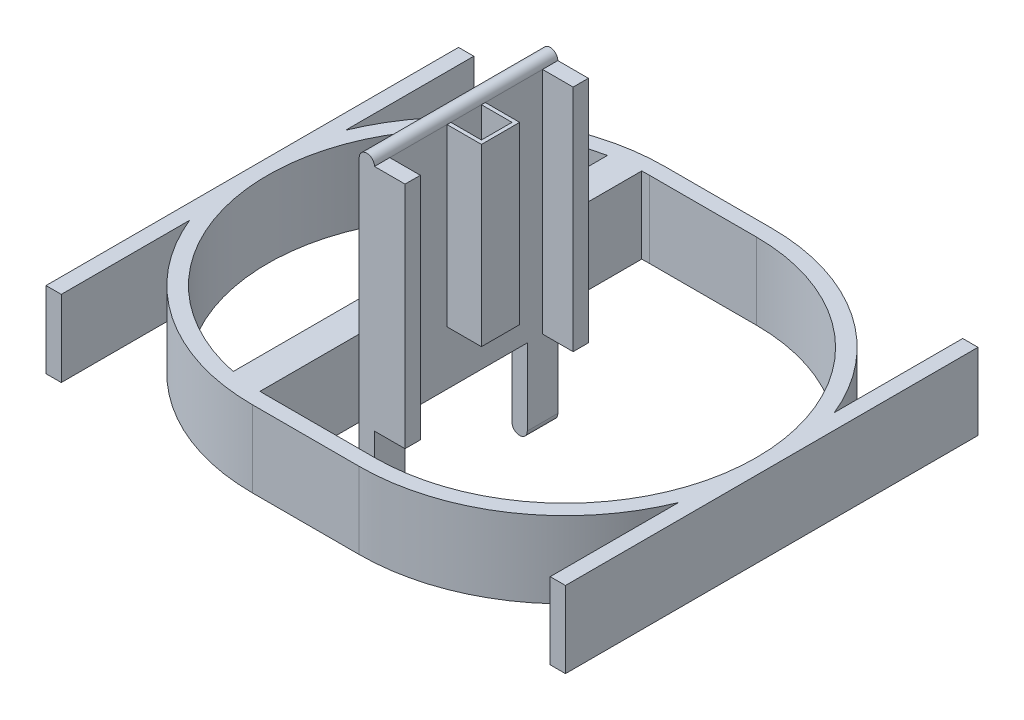
from build123d import *

# Parameters (mm, degrees)
EXTRUDE_1_DEPTH     = 10
SKETCH_9_W          = 24
SKETCH_9_H          = 40
EXTRUDE_5_DEPTH     = 2
SKETCH_10_R         = 1
EXTRUDE_6_DEPTH     = 24
SKETCH_11_W         = 16
SKETCH_11_H         = 15.152135862
CUT_EXTRUDE_2_DEPTH = 24
SKETCH_12_W         = 2
SKETCH_12_H         = 30
EXTRUDE_7_DEPTH     = 4
SKETCH_13_W         = 5
SKETCH_13_H         = 5
SKETCH_13_W_2       = 4
SKETCH_13_H_2       = 4
SKETCH_15_W         = 2
SKETCH_15_H         = 54
EXTRUDE_8_DEPTH     = 10


with BuildPart() as part:
    # 草图2 → 凸台-拉伸1 (new body)
    with BuildSketch(Plane(origin=(0, 0, 0), x_dir=(1, 0, 0), z_dir=(0, 1, 0))):
        with BuildLine():
            Line((-7, 27), (7, 27))
            ThreePointArc((7, 27), (34, 0), (7, -27))
            Line((7, -27), (-7, -27))
            ThreePointArc((-7, -27), (-34, 0), (-7, 27))
        make_face()
        with BuildLine():
            Line((-7, 25), (7, 25))
            ThreePointArc((7, 25), (32, 0), (7, -25))
            Line((7, -25), (-7, -25))
            ThreePointArc((-7, -25), (-7.50010007, -24.994997498), (-8, -24.979991994))
            Line((-8, -24.979991994), (-8, 24.979991994))
            ThreePointArc((-8, 24.979991994), (-7.50010007, 24.994997498), (-7, 25))
        make_face(mode=Mode.SUBTRACT)
        with BuildLine():
            Line((-12, -24.494897428), (-12, 24.494897428))
            ThreePointArc((-12, 24.494897428), (-32, 0), (-12, -24.494897428))
        make_face(mode=Mode.SUBTRACT)
    extrude(amount=EXTRUDE_1_DEPTH)

    # 草图9 → 凸台-拉伸5 (add)
    with BuildSketch(Plane(origin=(-8, 0, 0), x_dir=(0, 0, -1), z_dir=(1, 0, 0))):
        with Locations((0, 10)):
            Rectangle(SKETCH_9_W, SKETCH_9_H)
    extrude(amount=EXTRUDE_5_DEPTH)

    # 草图10 → 凸台-拉伸6 (add)
    with BuildSketch(Plane(origin=(0, 0, -12), x_dir=(-1, 0, 0), z_dir=(0, 0, -1))):
        with Locations((7, 30)):
            Circle(SKETCH_10_R)
        with Locations((7, -10)):
            Circle(SKETCH_10_R)
    extrude(amount=-EXTRUDE_6_DEPTH)

    # 草图11 → 切除-拉伸2 (cut)
    with BuildSketch(Plane(origin=(-6, 0, 0), x_dir=(0, 0, -1), z_dir=(1, 0, 0))):
        with Locations((0, -7.576067931)):
            Rectangle(SKETCH_11_W, SKETCH_11_H)
    extrude(amount=-CUT_EXTRUDE_2_DEPTH, mode=Mode.SUBTRACT)

    # 草图12 → 凸台-拉伸7 (add)
    with BuildSketch(Plane(origin=(-6, 0, 0), x_dir=(0, 0, -1), z_dir=(1, 0, 0))):
        with Locations((11, 15)):
            Rectangle(SKETCH_12_W, SKETCH_12_H)
        with Locations((-11, 15)):
            Rectangle(SKETCH_12_W, SKETCH_12_H)
    extrude(amount=EXTRUDE_7_DEPTH)

    # 扫描3: sweep along a path in 草图14
    with BuildLine(Plane(origin=(-6, 0, 0), x_dir=(0, 0, -1), z_dir=(1, 0, 0))) as sweep_3_path:
        Line((-2, 7.068163289), (-2, 30))
    # 草图13 → 扫描3 (sweep)
    with BuildSketch(Plane(origin=(0, 30, 0), x_dir=(1, 0, 0), z_dir=(0, 1, 0))):
        with Locations((-4, 0)):
            Rectangle(SKETCH_13_W, SKETCH_13_H)
        with Locations((-4, 0)):
            Rectangle(SKETCH_13_W_2, SKETCH_13_H_2, mode=Mode.SUBTRACT)
    sweep(path=sweep_3_path.line)

    # 草图15 → 凸台-拉伸8 (add)
    with BuildSketch(Plane.XZ):
        with Locations((-33, 0)):
            Rectangle(SKETCH_15_W, SKETCH_15_H)
        with Locations((33, 0)):
            Rectangle(SKETCH_15_W, SKETCH_15_H)
    extrude(amount=-EXTRUDE_8_DEPTH)


solid = part.part
